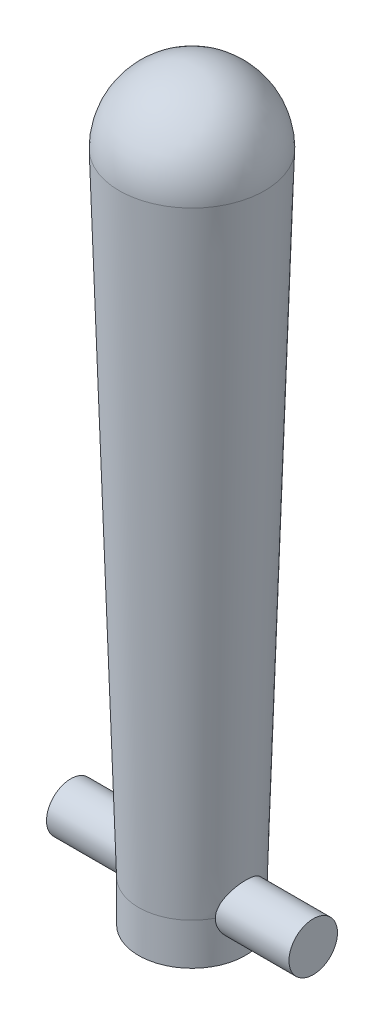
from build123d import *

# Parameters (mm, degrees)
BOSS_EXTRU_1_DEPTH      = 2.5
BOSS_EXTRU_1_DEPTH_BACK = 2.5
ESQUISSE2_R             = 0.5
SCALE1_SCALE            = 0.64015


with BuildPart() as part:
    # Esquisse1 → Révolution1 (revolve)
    with BuildSketch(Plane(origin=(0, 0, 0), x_dir=(0, 0, -1), z_dir=(1, 0, 0))):
        with BuildLine():
            Line((1.49716245, 12.907779617), (1.5, 13))
            ThreePointArc((1.5, 13), (1.060660172, 14.060660172), (0, 14.5))
            Line((0, 14.5), (0, -0.857830241))
            Line((0, -0.857830241), (1.1, -0.857830241))
            Line((1.1, -0.857830241), (1.1, 0))
            Line((1.1, 0), (1.49716245, 12.907779617))
        make_face()
    revolve(axis=Axis((0, 0, 0), (0, 1, 0)))

    # Esquisse2 → Boss.-Extru.1 (add, two sides: drawn at the far end of the back side and taken through both)
    with BuildSketch(Plane(origin=(0, 0, 0), x_dir=(0, 0, -1), z_dir=(1, 0, 0)).offset(-BOSS_EXTRU_1_DEPTH_BACK)):
        Circle(ESQUISSE2_R)
    extrude(amount=BOSS_EXTRU_1_DEPTH + BOSS_EXTRU_1_DEPTH_BACK)


with BuildPart() as part_1:
    # Scale1: scaled about (-2e-09, 7.215672935, 2e-09)
    add(part.part.scale(SCALE1_SCALE).moved(Location((-1e-09, 2.596559906, 1e-09))))


solid = part_1.part
